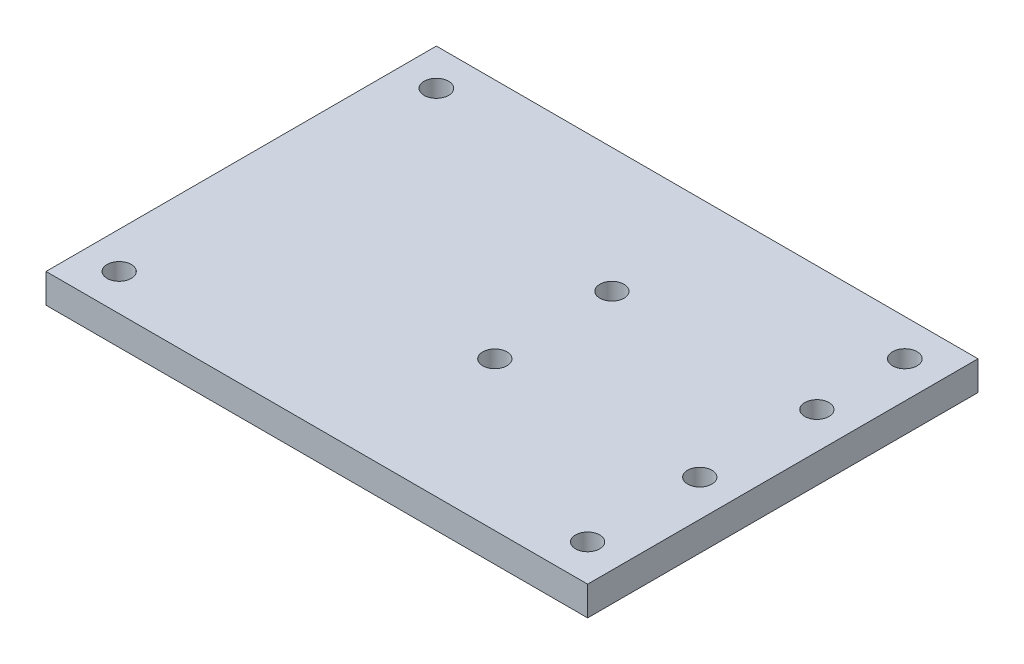
from build123d import *

# Parameters (mm, degrees)
SKETCH1_W           = 117.475
SKETCH1_H           = 84.668868
SKETCH1_R           = 2.6289
SKETCH1_R_2         = 2.667
BOSS_EXTRUDE1_DEPTH = 6.35
SKETCH2_R           = 2.6289
CUT_EXTRUDE1_DEPTH  = 7.35


with BuildPart() as part:
    # Sketch1 → Boss-Extrude1 (new body)
    with BuildSketch(Plane(origin=(0, 0, 0), x_dir=(1, 0, 0), z_dir=(0, 1, 0))):
        with Locations((58.7375, 42.334434)):
            Rectangle(SKETCH1_W, SKETCH1_H)
        with Locations((7.9375, 7.9375)):
            Circle(SKETCH1_R, mode=Mode.SUBTRACT)
        with Locations((109.5375, 7.9375)):
            Circle(SKETCH1_R, mode=Mode.SUBTRACT)
        with Locations((7.9375, 76.731368)):
            Circle(SKETCH1_R_2, mode=Mode.SUBTRACT)
        with Locations((109.5375, 76.731368)):
            Circle(SKETCH1_R_2, mode=Mode.SUBTRACT)
    extrude(amount=BOSS_EXTRUDE1_DEPTH)

    # Sketch2 → Cut-Extrude1 (cut, through all)
    with BuildSketch(Plane(origin=(0, 6.35, 0), x_dir=(1, 0, 0), z_dir=(0, 1, 0))):
        with Locations((109.5375, 32.256790414)):
            Circle(SKETCH2_R)
        with Locations((109.5375, 57.656790414)):
            Circle(SKETCH2_R)
        with Locations((65.0875, 57.656790414)):
            Circle(SKETCH2_R)
        with Locations((65.0875, 32.256790414)):
            Circle(SKETCH2_R)
    extrude(amount=-CUT_EXTRUDE1_DEPTH, mode=Mode.SUBTRACT)


solid = part.part
